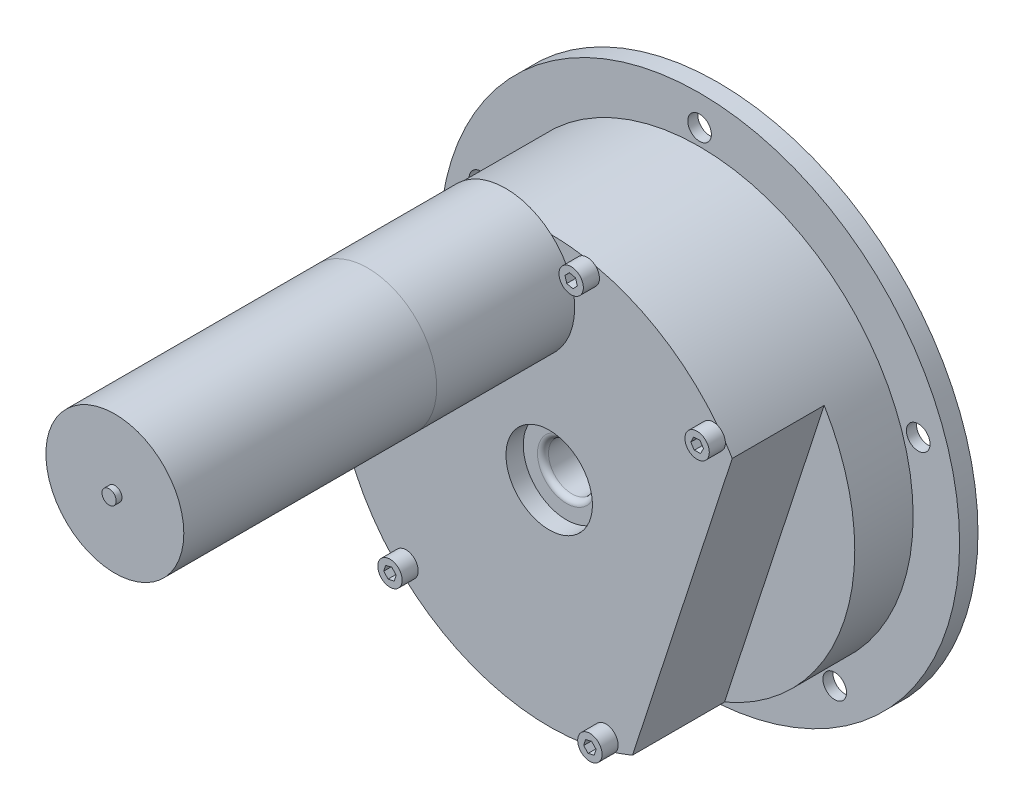
from build123d import *

# Parameters (mm, degrees)
FILLET1_R          = 1.524
SKETCH3_R          = 56.007
EXTRUDE1_DEPTH     = 2.6416
EXTRUDE3_REACH     = 7.08
SKETCH5_R          = 3.2639
CHAMFER1_SIZE      = 3.9878
CHAMFER1_SIZE2     = 2.302357403
EXTRUDE4_DEPTH     = 25.4
SKETCH7_R          = 19.05
EXTRUDE5_DEPTH     = 107.95
SKETCH9_R          = 3.3655
EXTRUDE6_DEPTH     = 4.445
SKETCH10_R         = 1.9685
EXTRUDE7_DEPTH     = 24.765
CUT_EXTRUDE1_START = 1.5875
SKETCH15_R         = 1.9685
CUT_EXTRUDE1_DEPTH = 24.1775


with BuildPart() as part:
    # Sketch2 → Revolve1 (revolve)
    with BuildSketch(Plane(origin=(0, 0, 0), x_dir=(0, 0, -1), z_dir=(1, 0, 0))):
        Polygon((0, 6.477), (0, 71.8185), (-5.08, 71.8185), (-5.08, 58.9915), (-46.609, 58.9915), (-46.609, 11.938), (-41.8465, 11.938), (-41.8465, 6.477), align=None)
    revolve(axis=Axis((0, 0, 46.609), (0, 0, -1)))

    # Fillet1
    fillet1_edges = [part.edges().sort_by_distance(p)[0] for p in [
        (0, -6.477, 41.8465),
    ]]
    fillet(fillet1_edges, radius=FILLET1_R)

    # Sketch3 → Extrude1 (cut)
    with BuildSketch(Plane(origin=(0, 0, 0), x_dir=(-1, 0, 0), z_dir=(0, 0, -1))):
        Circle(SKETCH3_R)
    extrude(amount=-EXTRUDE1_DEPTH, mode=Mode.SUBTRACT)

    # Sketch5 → Extrude3 (cut, up to next)
    with BuildSketch(Plane.XY.offset(5.08), mode=Mode.PRIVATE) as extrude3_sk1:
        with Locations((0, 63.5)):
            Circle(SKETCH5_R)
    extrude3_tool1 = extrude(extrude3_sk1.sketch, amount=-EXTRUDE3_REACH, mode=Mode.PRIVATE) & part.part
    add(extrude3_tool1.solids().sort_by_distance((0, 63.5, 5.08))[0], mode=Mode.SUBTRACT)
    # Sketch5 → Extrude3 (cut, up to next)
    with BuildSketch(Plane.XY.offset(5.08), mode=Mode.PRIVATE) as extrude3_sk2:
        with Locations((60.392088785, 19.622579143)):
            Circle(SKETCH5_R)
    extrude3_tool2 = extrude(extrude3_sk2.sketch, amount=-EXTRUDE3_REACH, mode=Mode.PRIVATE) & part.part
    add(extrude3_tool2.solids().sort_by_distance((60.392089, 19.622579, 5.08))[0], mode=Mode.SUBTRACT)
    # Sketch5 → Extrude3 (cut, up to next)
    with BuildSketch(Plane.XY.offset(5.08), mode=Mode.PRIVATE) as extrude3_sk3:
        with Locations((37.324363521, -51.372579143)):
            Circle(SKETCH5_R)
    extrude3_tool3 = extrude(extrude3_sk3.sketch, amount=-EXTRUDE3_REACH, mode=Mode.PRIVATE) & part.part
    add(extrude3_tool3.solids().sort_by_distance((37.324364, -51.372579, 5.08))[0], mode=Mode.SUBTRACT)
    # Sketch5 → Extrude3 (cut, up to next)
    with BuildSketch(Plane.XY.offset(5.08), mode=Mode.PRIVATE) as extrude3_sk4:
        with Locations((-37.324363521, -51.372579143)):
            Circle(SKETCH5_R)
    extrude3_tool4 = extrude(extrude3_sk4.sketch, amount=-EXTRUDE3_REACH, mode=Mode.PRIVATE) & part.part
    add(extrude3_tool4.solids().sort_by_distance((-37.324364, -51.372579, 5.08))[0], mode=Mode.SUBTRACT)
    # Sketch5 → Extrude3 (cut, up to next)
    with BuildSketch(Plane.XY.offset(5.08), mode=Mode.PRIVATE) as extrude3_sk5:
        with Locations((-60.392088785, 19.622579143)):
            Circle(SKETCH5_R)
    extrude3_tool5 = extrude(extrude3_sk5.sketch, amount=-EXTRUDE3_REACH, mode=Mode.PRIVATE) & part.part
    add(extrude3_tool5.solids().sort_by_distance((-60.392089, 19.622579, 5.08))[0], mode=Mode.SUBTRACT)

    # Chamfer1
    chamfer1_edges = [part.edges().sort_by_distance(p)[0] for p in [
        (-3.2639, 63.5, 0),
        (57.128188785, 19.622579143, 0),
        (34.060463521, -51.372579143, 0),
        (-40.588263521, -51.372579143, 0),
        (-63.655988785, 19.622579143, 0),
    ]]
    chamfer1_side = [part.faces().sort_by_distance(p)[0] for p in [
        (0, -69.787166065, 0),
    ]]
    chamfer(chamfer1_edges, length=CHAMFER1_SIZE, length2=CHAMFER1_SIZE2, reference=chamfer1_side[0])

    # Sketch6 → Extrude4 (cut)
    with BuildSketch(Plane.XY.offset(46.609)):
        Polygon((50.54556585, 30.416160921), (23.014050942, -54.317129264), (47.170886456, -62.166160921), (74.702401364, 22.567129264), align=None)
    extrude(amount=-EXTRUDE4_DEPTH, mode=Mode.SUBTRACT)

    # Sketch7 → Extrude5 (add)
    with BuildSketch(Plane.XY.offset(46.609)):
        with Locations((-12.023794238, 44.70269952)):
            Circle(SKETCH7_R)
    extrude(amount=EXTRUDE5_DEPTH)

    # Sketch9 → Extrude6 (add)
    with BuildSketch(Plane.XY.offset(46.609)):
        with Locations((45.289737364, 33.164222372)):
            Circle(SKETCH9_R)
        Polygon((46.260636305, 31.696529201), (47.046246406, 33.271198934), (46.075347464, 34.738892106), (44.318838422, 34.631915543), (43.533228322, 33.057245809), (44.504127263, 31.589552638), align=None, mode=Mode.SUBTRACT)
        with Locations((10.504871796, 55.142303403)):
            Circle(SKETCH9_R)
        Polygon((12.215906667, 54.731052055), (11.716543346, 56.418477394), (10.005508475, 56.829728741), (8.793836925, 55.55355475), (9.293200246, 53.866129412), (11.004235117, 53.454878064), align=None, mode=Mode.SUBTRACT)
        with Locations((15.674172573, -53.901264087)):
            Circle(SKETCH9_R)
        Polygon((13.962925135, -54.311630029), (15.173936185, -55.588430811), (16.885183622, -55.178064869), (17.38542001, -53.490898144), (16.174408961, -52.214097362), (14.463161523, -52.624463305), align=None, mode=Mode.SUBTRACT)
        with Locations((-56.011502863, 3.706413765)):
            Circle(SKETCH9_R)
        Polygon((-55.811839617, 5.454813773), (-57.425830063, 4.753527212), (-57.625493309, 3.005127204), (-56.211166109, 1.958013757), (-54.597175663, 2.659300318), (-54.397512417, 4.407700326), align=None, mode=Mode.SUBTRACT)
        with Locations((-39.544118158, -39.840791598)):
            Circle(SKETCH9_R)
        Polygon((-40.732661518, -38.543050222), (-41.262266837, -40.221229654), (-40.073723476, -41.51897103), (-38.355574797, -41.138532974), (-37.825969478, -39.460353542), (-39.014512839, -38.162612166), align=None, mode=Mode.SUBTRACT)
    extrude(amount=EXTRUDE6_DEPTH)

    # Sketch10 → Extrude7 (add)
    with BuildSketch(Plane.XY.offset(154.559)):
        with Locations((-12.023794238, 44.70269952)):
            Circle(SKETCH10_R)
    extrude(amount=EXTRUDE7_DEPTH)

    # Sketch15 → Cut-Extrude1 (cut, through all)
    with BuildSketch(Plane.XY.offset(154.559).offset(CUT_EXTRUDE1_START)):
        with Locations((-12.023794238, 44.70269952)):
            Circle(SKETCH15_R)
    extrude(amount=CUT_EXTRUDE1_DEPTH, mode=Mode.SUBTRACT)


solid = part.part
